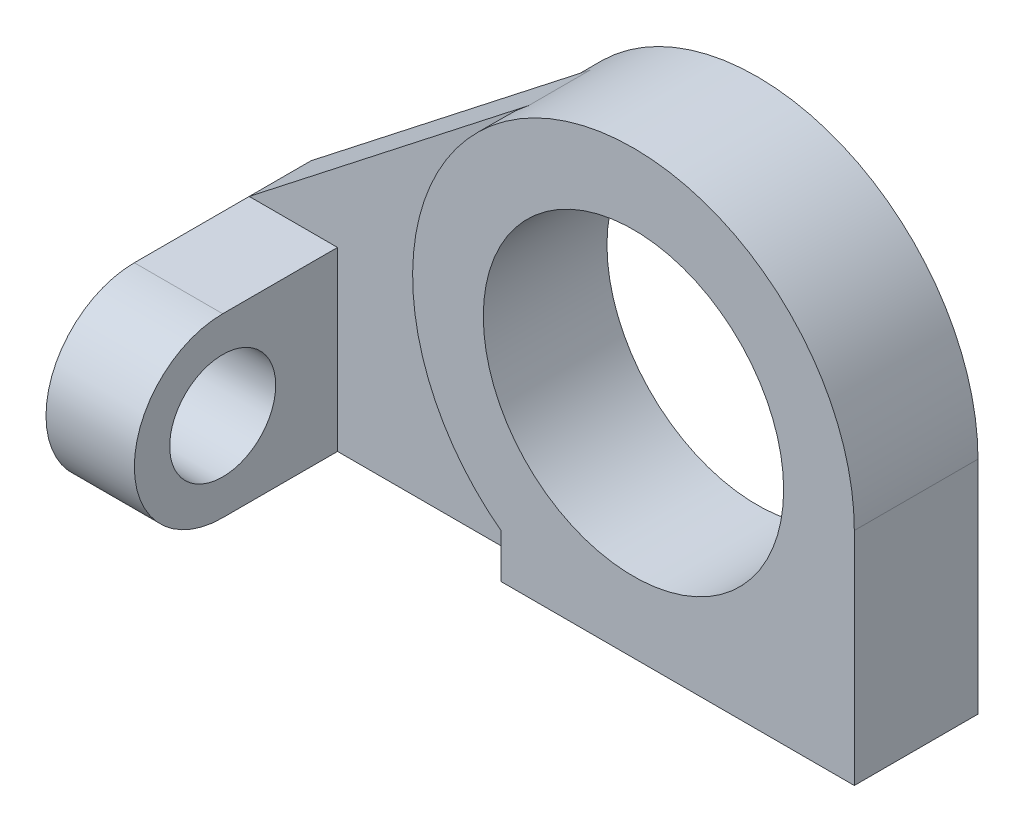
from build123d import *

# Parameters (mm, degrees)
IZIM1_R                           = 17
Y_KSEKLIK_EKSTR_ZYON1_DEPTH       = 14
Y_KSEKLIK_EKSTR_ZYON2_DEPTH       = 14
IZIM2_W                           = 7
IZIM2_H                           = 16
Y_KSEKLIK_EKSTR_ZYON3_DEPTH       = 4
IZIM2_3_R                         = 6
Y_KSEKLIK_EKSTR_ZYON4_DEPTH       = 10
Y_KSEKLIK_EKSTR_ZYON11_DEPTH      = 10
Y_KSEKLIK_EKSTR_ZYON11_DEPTH_BACK = 4
IZIM4_W                           = 7
IZIM4_H                           = 16
Y_KSEKLIK_EKSTR_ZYON12_DEPTH      = 3.5


with BuildPart() as part:
    # Çizim1 → Yükseklik-Ekstrüzyon1 (new body)
    with BuildSketch(Plane.XY):
        with BuildLine():
            ThreePointArc((40, 25), (3.819660113, 47.360679775), (0, 5))
            ThreePointArc((0, 5), (7.09430585, 1.282917549), (15, 0))
            ThreePointArc((15, 0), (32.67766953, 7.32233047), (40, 25))
        make_face()
        with Locations((15, 25)):
            Circle(IZIM1_R, mode=Mode.SUBTRACT)
    extrude(amount=Y_KSEKLIK_EKSTR_ZYON1_DEPTH)

    # Çizim1<3> → Yükseklik-Ekstrüzyon2 (add)
    with BuildSketch(Plane.XY):
        with BuildLine():
            Line((0, 5), (0, 0))
            Line((0, 0), (15, 0))
            ThreePointArc((15, 0), (7.09430585, 1.282917549), (0, 5))
        make_face()
        with BuildLine():
            ThreePointArc((40, 25), (32.67766953, 7.32233047), (15, 0))
            Line((15, 0), (40, 0))
            Line((40, 0), (40, 25))
        make_face()
    extrude(amount=Y_KSEKLIK_EKSTR_ZYON2_DEPTH)



with BuildPart() as body_2:
    # Çizim2 → Yükseklik-Ekstrüzyon3 (new body)
    with BuildSketch(Plane(origin=(-32, 0, 0), x_dir=(0, 0, -1), z_dir=(1, 0, 0))):
        with Locations((-7, 8)):
            Rectangle(IZIM2_W, IZIM2_H)
    extrude(amount=Y_KSEKLIK_EKSTR_ZYON3_DEPTH)

    # Çizim2<3> → Yükseklik-Ekstrüzyon4 (add)
    with BuildSketch(Plane(origin=(-32, 0, 0), x_dir=(0, 0, -1), z_dir=(1, 0, 0))):
        with BuildLine():
            Line((-23.5, 0), (-10.5, 0))
            Line((-10.5, 0), (-10.5, 16))
            Line((-10.5, 16), (-3.5, 16))
            Line((-3.5, 16), (-3.5, 20))
            Line((-3.5, 20), (-23.5, 20))
            ThreePointArc((-23.5, 20), (-33.5, 10), (-23.5, 0))
        make_face()
        with Locations((-23.5, 10)):
            Circle(IZIM2_3_R, mode=Mode.SUBTRACT)
    extrude(amount=Y_KSEKLIK_EKSTR_ZYON4_DEPTH)

    # Çizim4 → Yükseklik-Ekstrüzyon11 (add, two sides: drawn at the far end of the back side and taken through both)
    with BuildSketch(Plane(origin=(-32, 0, 0), x_dir=(0, 0, -1), z_dir=(1, 0, 0)).offset(-Y_KSEKLIK_EKSTR_ZYON11_DEPTH_BACK)):
        with Locations((-7, 8)):
            Rectangle(IZIM4_W, IZIM4_H)
    extrude(amount=Y_KSEKLIK_EKSTR_ZYON11_DEPTH + Y_KSEKLIK_EKSTR_ZYON11_DEPTH_BACK)


with BuildPart() as part_1:
    add(part.part)

    add(body_2.part)  # Yükseklik-Ekstrüzyon12 merges body 2
    # Çizim3 → Yükseklik-Ekstrüzyon12 (add, symmetric)
    with BuildSketch(Plane.XY.offset(7)):
        with BuildLine():
            Line((-32, 20), (-0.393483787, 44.698747597))
            ThreePointArc((-0.393483787, 44.698747597), (-9.998772057, 24.752218594), (0, 5))
            Line((0, 5), (0, 0))
            Line((0, 0), (-22, 0))
            Line((-22, 0), (-22, 20))
            Line((-22, 20), (-32, 20))
        make_face()
    extrude(amount=Y_KSEKLIK_EKSTR_ZYON12_DEPTH, both=True)


solid = part_1.part
